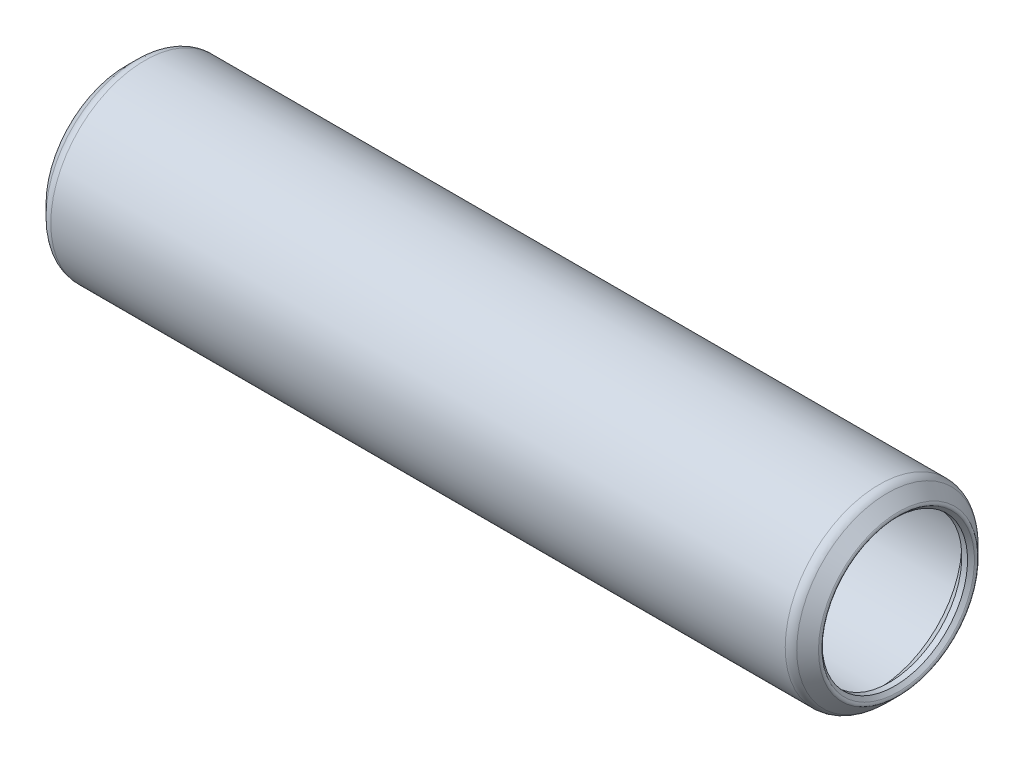
from build123d import *


with BuildPart() as part:
    # Sketch1 → Revolve1 (revolve)
    with BuildSketch(Plane.XY):
        with BuildLine():
            Line((-0.445028708, 3.689878708), (-0.2794, 3.52425))
            Line((-0.2794, 3.52425), (0, 3.52425))
            Line((0, 3.52425), (0.5588, 4.08305))
            Line((0.5588, 4.08305), (35.9918, 4.08305))
            Line((35.9918, 4.08305), (36.5506, 3.52425))
            Line((36.5506, 3.52425), (36.83, 3.52425))
            Line((36.83, 3.52425), (36.995628708, 3.689878708))
            ThreePointArc((36.995628708, 3.689878708), (37.032826147, 3.779681269), (36.995628708, 3.869483831))
            Line((36.995628708, 3.869483831), (36.469481269, 4.395631269))
            ThreePointArc((36.469481269, 4.395631269), (36.288193502, 4.516763883), (36.07435, 4.5593))
            Line((36.07435, 4.5593), (0.47625, 4.5593))
            ThreePointArc((0.47625, 4.5593), (0.262406498, 4.516763883), (0.081118731, 4.395631269))
            Line((0.081118731, 4.395631269), (-0.445028708, 3.869483831))
            ThreePointArc((-0.445028708, 3.869483831), (-0.482226147, 3.779681269), (-0.445028708, 3.689878708))
        make_face()
    revolve(axis=Axis((36.5506, 0, 0), (-1, 0, 0)))


solid = part.part
